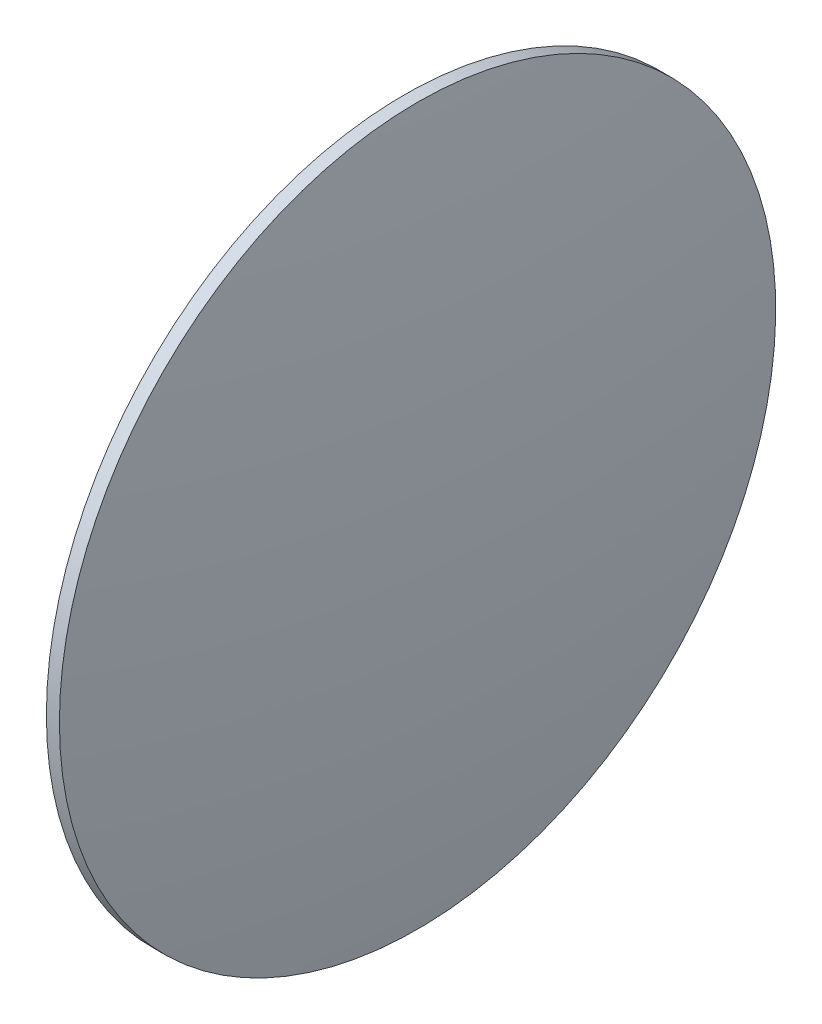
from build123d import *


with BuildPart() as part:
    # Sketch3 → Revolve1 (revolve)
    with BuildSketch(Plane.XY):
        with BuildLine():
            Line((0, 27.476049509), (1, 27.476049509))
            ThreePointArc((1, 27.476049509), (2.421679293, 13.770705673), (2.896323347, 0))
            Line((2.896323347, 0), (0, 0))
            Line((0, 0), (0, 27.476049509))
        make_face()
    revolve(axis=Axis((-100, 0, 0), (1, 0, 0)))


solid = part.part
